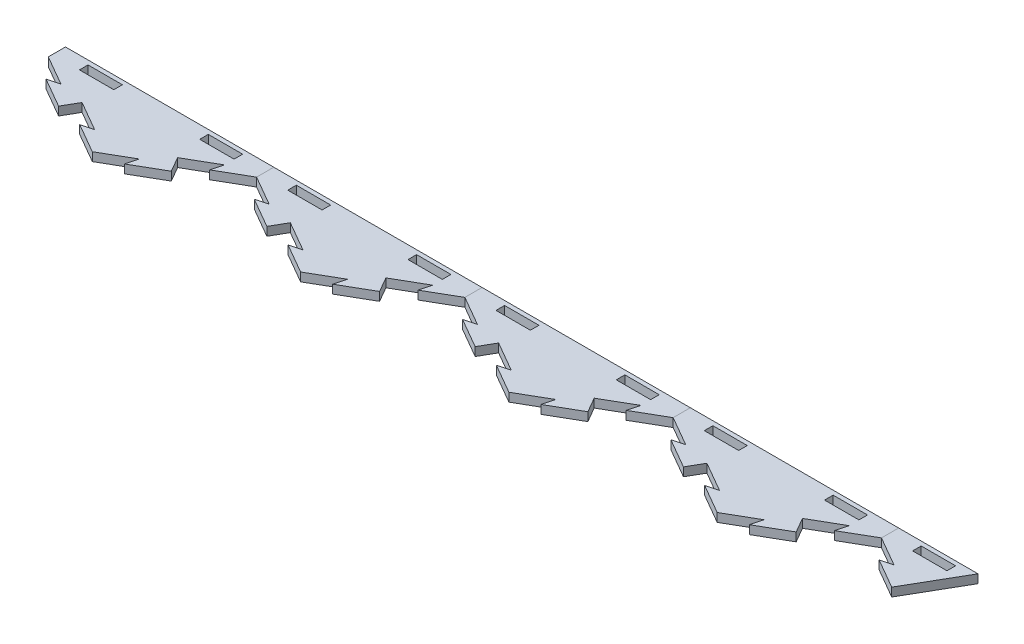
from build123d import *

# Parameters (mm, degrees)
BOSS_EXTRUDE1_DEPTH = 6.35
CUT_EXTRUDE4_DEPTH  = 155.110195964
BOSS_EXTRUDE4_DEPTH = 6.35
CIRPATTERN1_COUNT   = 2
CIRPATTERN1_ANGLE   = 60
SKETCH12_W          = 153.979316792
SKETCH12_H          = 120.65
CUT_EXTRUDE5_DEPTH  = 155.110195964
SKETCH13_W          = 25.4
SKETCH13_H          = 6.35
CUT_EXTRUDE6_DEPTH  = 90.126497182
LPATTERN1_COUNT     = 5
LPATTERN1_PITCH     = 153.979316882
LPATTERN1_2_COUNT   = 2
LPATTERN1_2_PITCH   = 153.979316882
SKETCH14_W          = 25.4
SKETCH14_H          = 6.35
CUT_EXTRUDE7_DEPTH  = 695.360232872
SKETCH15_W          = 58.658787349
SKETCH15_H          = 29.425738686
CUT_EXTRUDE8_DEPTH  = 600.270912242


with BuildPart() as part:
    # Sketch1 → Boss-Extrude1 (new body)
    with BuildSketch(Plane(origin=(0, 0, 0), x_dir=(1, 0, 0), z_dir=(0, 1, 0))):
        Polygon((-76.989658396, 0), (0, -44.45), (76.989658396, 0), (76.989658396, 88.9), (0, 133.35), (-76.989658396, 88.9), align=None)
    extrude(amount=-BOSS_EXTRUDE1_DEPTH)

    # Sketch10 → Cut-Extrude4 (cut, through all)
    with BuildSketch(Plane(origin=(0, 0, 0), x_dir=(1, 0, 0), z_dir=(0, 1, 0))):
        Polygon((-21.997045256, -31.75), (-13.322783942, -29.425738686), (-35.319829198, -16.725738686), (-38.494829198, -22.225), align=None)
    cut_extrude4 = extrude(amount=-CUT_EXTRUDE4_DEPTH, mode=Mode.SUBTRACT)

    # Sketch11 → Boss-Extrude4 (add)
    with BuildSketch(Plane(origin=(0, 0, 0), x_dir=(1, 0, 0), z_dir=(0, 1, 0))):
        Polygon((-38.494829198, -22.225), (-41.669829198, -27.724261314), (-63.666874454, -15.024261314), (-54.99261314, -12.7), align=None)
    boss_extrude4 = extrude(amount=-BOSS_EXTRUDE4_DEPTH)

    # CirPattern1: Cut-Extrude4, Boss-Extrude4 ×2 about axis
    cirpattern1_axis = Axis((0, 0, -44.45), (0, 1, 0))
    add([cut_extrude4.rotate(cirpattern1_axis, i * CIRPATTERN1_ANGLE / (CIRPATTERN1_COUNT - 1)) for i in range(1, CIRPATTERN1_COUNT)], mode=Mode.SUBTRACT)
    add([boss_extrude4.rotate(cirpattern1_axis, i * CIRPATTERN1_ANGLE / (CIRPATTERN1_COUNT - 1)) for i in range(1, CIRPATTERN1_COUNT)])

    # Sketch12 → Cut-Extrude5 (cut, through all)
    with BuildSketch(Plane(origin=(0, 0, 0), x_dir=(1, 0, 0), z_dir=(0, 1, 0))):
        with Locations((0, 73.025)):
            Rectangle(SKETCH12_W, SKETCH12_H)
    extrude(amount=-CUT_EXTRUDE5_DEPTH, mode=Mode.SUBTRACT)

    # Sketch13 → Cut-Extrude6 (cut, through all)
    with BuildSketch(Plane(origin=(0, 0, 0), x_dir=(1, 0, 0), z_dir=(0, 1, 0))):
        with Locations((-44.45, 6.35)):
            Rectangle(SKETCH13_W, SKETCH13_H)
        with Locations((44.45, 6.35)):
            Rectangle(SKETCH13_W, SKETCH13_H)
    extrude(amount=-CUT_EXTRUDE6_DEPTH, mode=Mode.SUBTRACT)


with BuildPart() as lpattern1_1:
    # LPattern1: pattern copy
    add(part.part.moved(Location(Vector(1, 0, 0) * (1 * LPATTERN1_PITCH))))


with BuildPart() as lpattern1_2:
    # LPattern1: pattern copy
    add(part.part.moved(Location(Vector(1, 0, 0) * (2 * LPATTERN1_PITCH))))


with BuildPart() as lpattern1_3:
    # LPattern1: pattern copy
    add(part.part.moved(Location(Vector(1, 0, 0) * (3 * LPATTERN1_PITCH))))


with BuildPart() as lpattern1_4:
    # LPattern1: pattern copy
    add(part.part.moved(Location(Vector(1, 0, 0) * (4 * LPATTERN1_PITCH))))


with BuildPart() as lpattern1_2_1:
    # LPattern1 2: pattern copy
    add(part.part.moved(Location(Vector(-1, 0, 0) * (1 * LPATTERN1_2_PITCH))))


with BuildPart() as cut_extrude7_tool:
    # Sketch14 → Cut-Extrude7 (new, through all)
    # profile 1 of 2: a face of its own
    with BuildSketch(Plane(origin=(0, 0, 0), x_dir=(1, 0, 0), z_dir=(0, 1, 0))):
        Polygon((593.920222272, -31.75), (615.917267528, -44.45), (637.914312784, -31.75), (635.59005147, -40.424261314), (657.587096726, -27.724261314), (651.237096726, -16.725738686), (673.234141982, -4.025738686), (670.909880668, -12.7), (692.906925924, 0), (692.906925924, 12.7), (597.586396481, 12.7), (580.59743833, -16.725738686), (602.594483586, -29.425738686), align=None)
        with Locations((660.367267528, 6.35)):
            Rectangle(SKETCH14_W, SKETCH14_H, mode=Mode.SUBTRACT)
    # profile 2 of 2: a face of its own
    with BuildSketch(Plane(origin=(0, 0, 0), x_dir=(1, 0, 0), z_dir=(0, 1, 0))):
        Polygon((-230.968975278, -44.45), (-153.979316882, -44.45), (-134.30653294, -40.424261314), (-112.309487684, -27.724261314), (-135.648445835, 12.7), (-230.968975278, 12.7), align=None)
    extrude(amount=-CUT_EXTRUDE7_DEPTH)


with BuildPart() as lpattern1_4_1:
    add(lpattern1_4.part)

    # Cut-Extrude7: cut by cut_extrude7_tool
    add(cut_extrude7_tool.part, mode=Mode.SUBTRACT)


with BuildPart() as lpattern1_2_1_1:
    add(lpattern1_2_1.part)

    # Cut-Extrude7: cut by cut_extrude7_tool
    add(cut_extrude7_tool.part, mode=Mode.SUBTRACT)

    # Sketch15 → Cut-Extrude8 (cut, through all)
    with BuildSketch(Plane(origin=(0, 0, 0), x_dir=(1, 0, 0), z_dir=(0, 1, 0))):
        with Locations((-106.319052161, -2.012869343)):
            Rectangle(SKETCH15_W, SKETCH15_H)
    extrude(amount=-CUT_EXTRUDE8_DEPTH, mode=Mode.SUBTRACT)


solid = Compound([part.part, lpattern1_1.part, lpattern1_2.part, lpattern1_3.part, lpattern1_4_1.part])
